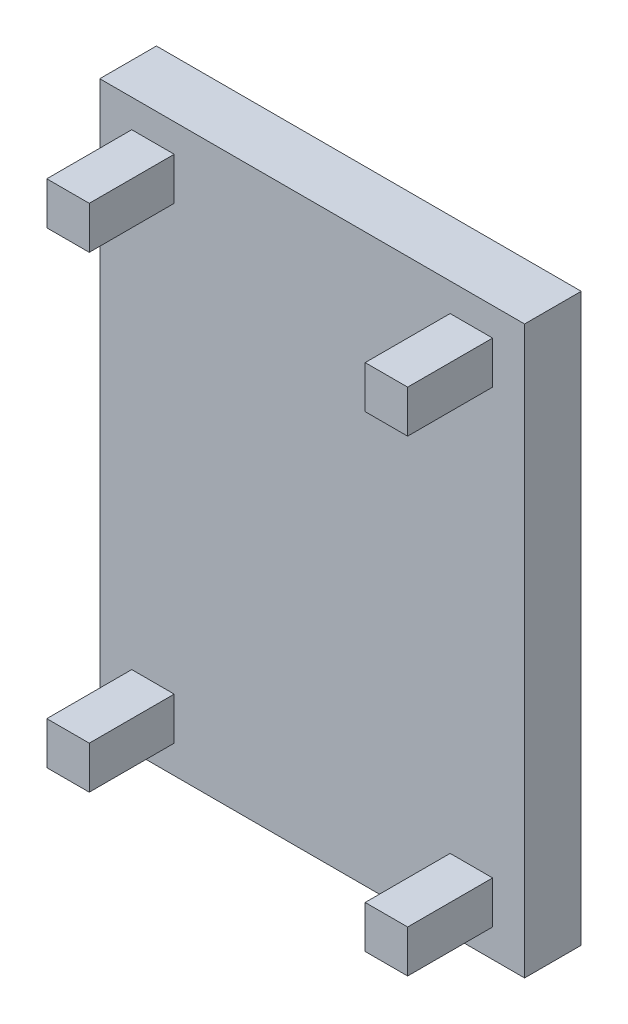
from build123d import *

# Parameters (mm, degrees)
SKETCH_1_W      = 1500
SKETCH_1_H      = 2000
EXTRUDE_1_DEPTH = 200
SKETCH_2_W      = 150
SKETCH_2_H      = 150
EXTRUDE_2_DEPTH = 300


with BuildPart() as part:
    # 草图1 → 凸台-拉伸1 (new body)
    with BuildSketch(Plane.XY):
        Rectangle(SKETCH_1_W, SKETCH_1_H)
    extrude(amount=EXTRUDE_1_DEPTH)

    # 草图2 → 凸台-拉伸2 (add)
    with BuildSketch(Plane.XY.offset(200)):
        with Locations((-562.101095116, 825.42306477)):
            Rectangle(SKETCH_2_W, SKETCH_2_H)
        with Locations((562.101095116, 825.42306477)):
            Rectangle(SKETCH_2_W, SKETCH_2_H)
        with Locations((562.101095116, -825.42306477)):
            Rectangle(SKETCH_2_W, SKETCH_2_H)
        with Locations((-562.101095116, -825.42306477)):
            Rectangle(SKETCH_2_W, SKETCH_2_H)
    extrude(amount=EXTRUDE_2_DEPTH)


solid = part.part
